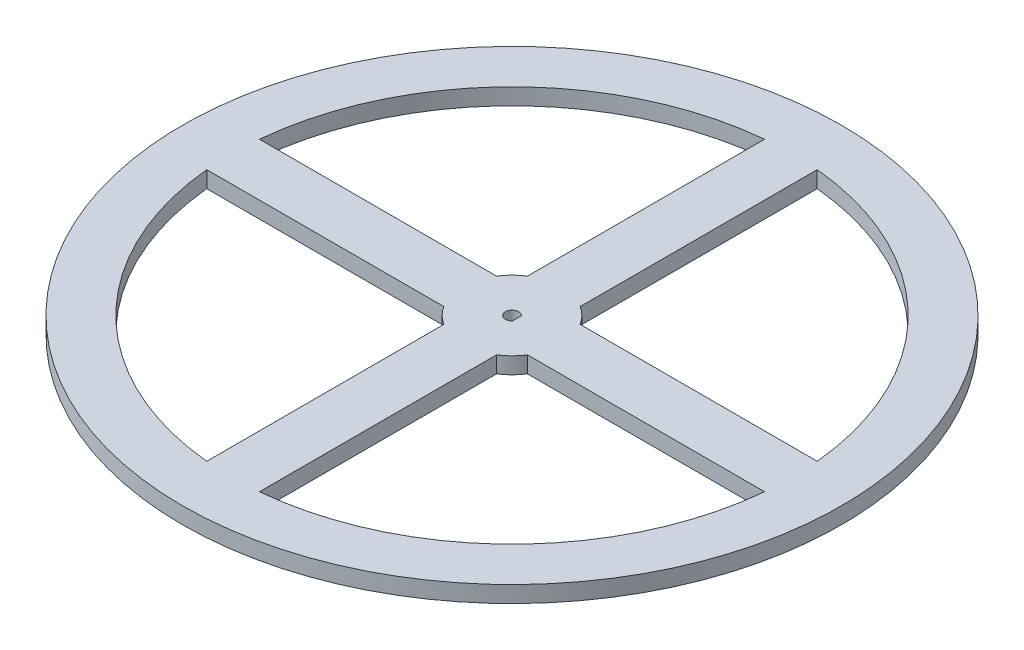
from build123d import *

# Parameters (mm, degrees)
SKETCH2_R           = 100
BOSS_EXTRUDE1_DEPTH = 5
CUT_EXTRUDE2_DEPTH  = 5


with BuildPart() as part:
    # Sketch2 → Boss-Extrude1 (new body)
    with BuildSketch(Plane(origin=(0, 0, 0), x_dir=(1, 0, 0), z_dir=(0, 1, 0))):
        Circle(SKETCH2_R)
        with BuildLine():
            Line((-8, -12.68857754), (-8, -84.622691992))
            ThreePointArc((-8, -84.622691992), (-60.104076401, -60.104076401), (-84.622691992, -8))
            Line((-84.622691992, -8), (-12.68857754, -8))
            ThreePointArc((-12.68857754, -8), (-10.606601718, -10.606601718), (-8, -12.68857754))
        make_face(mode=Mode.SUBTRACT)
        with BuildLine():
            Line((12.68857754, -8), (84.622691992, -8))
            ThreePointArc((84.622691992, -8), (60.104076401, -60.104076401), (8, -84.622691992))
            Line((8, -84.622691992), (8, -12.68857754))
            ThreePointArc((8, -12.68857754), (10.606601718, -10.606601718), (12.68857754, -8))
        make_face(mode=Mode.SUBTRACT)
        with BuildLine():
            Line((-8, 84.622691992), (-8, 12.68857754))
            ThreePointArc((-8, 12.68857754), (-10.606601718, 10.606601718), (-12.68857754, 8))
            Line((-12.68857754, 8), (-84.622691992, 8))
            ThreePointArc((-84.622691992, 8), (-60.104076401, 60.104076401), (-8, 84.622691992))
        make_face(mode=Mode.SUBTRACT)
        with BuildLine():
            ThreePointArc((8, 84.622691992), (60.104076401, 60.104076401), (84.622691992, 8))
            Line((84.622691992, 8), (12.68857754, 8))
            ThreePointArc((12.68857754, 8), (10.606601718, 10.606601718), (8, 12.68857754))
            Line((8, 12.68857754), (8, 84.622691992))
        make_face(mode=Mode.SUBTRACT)
    extrude(amount=BOSS_EXTRUDE1_DEPTH)

    # Sketch3 → Cut-Extrude2 (cut)
    with BuildSketch(Plane.XZ):
        with BuildLine():
            Line((1.5, 0), (1.5, -1.322875656))
            ThreePointArc((1.5, -1.322875656), (-2, 0), (1.5, 1.322875656))
            Line((1.5, 1.322875656), (1.5, 0))
        make_face()
    extrude(amount=-CUT_EXTRUDE2_DEPTH, mode=Mode.SUBTRACT)


solid = part.part
